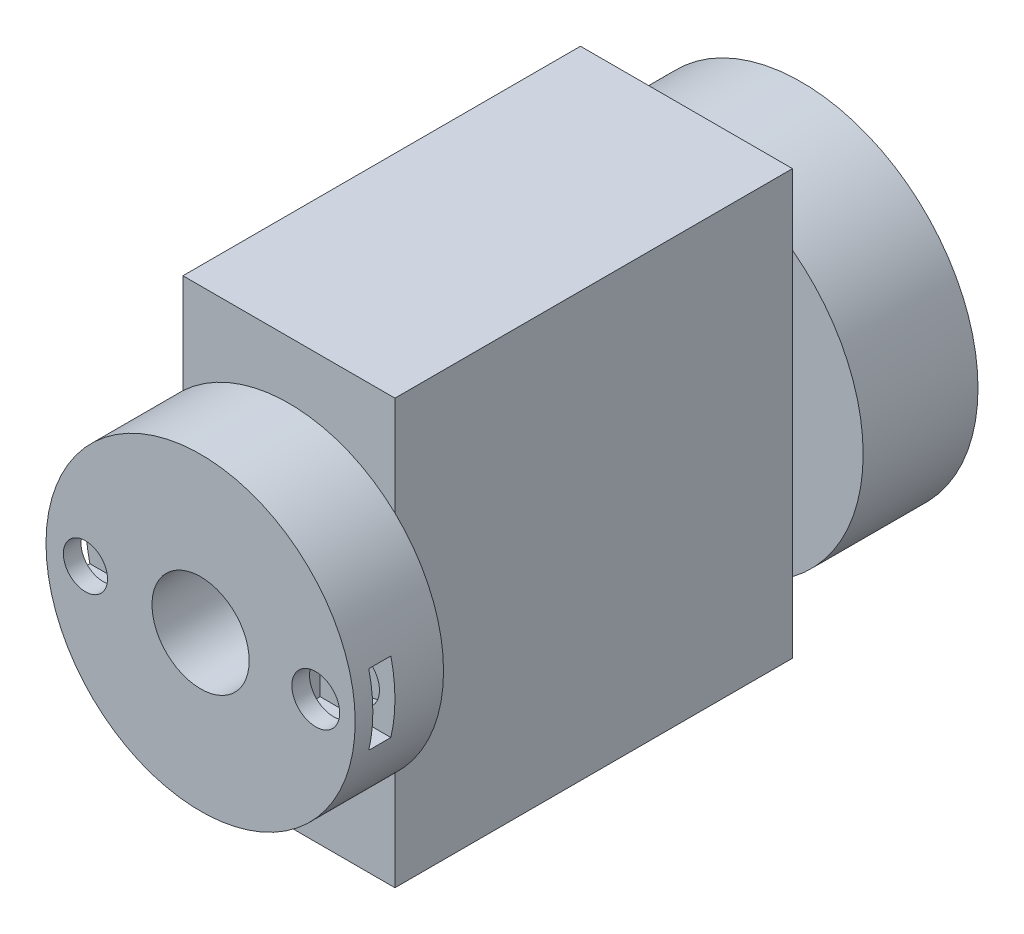
from build123d import *

# Parameters (mm, degrees)
ESQUISSE1_R                  = 17.5
BOSS_EXTRU_1_DEPTH           = 10
ESQUISSE3_W                  = 8
ESQUISSE3_H                  = 8
BOSS_EXTRU_3_DEPTH           = 4.5
ESQUISSE4_W                  = 2.5
ESQUISSE4_H                  = 8
ENL_V_MAT_EXTRU_1_DEPTH      = 1
ENL_V_MAT_EXTRU_1_DEPTH_BACK = 8
ESQUISSE5_R                  = 2.5
ENL_V_MAT_EXTRU_2_DEPTH      = 10.5
ESQUISSE6_W                  = 8
ESQUISSE6_H                  = 8
ESQUISSE6_R                  = 2.5
ENL_V_MAT_EXTRU_3_DEPTH      = 4.5
ESQUISSE7_W                  = 2.5
ESQUISSE7_H                  = 8
ENL_V_MAT_EXTRU_4_DEPTH      = 1
ENL_V_MAT_EXTRU_4_DEPTH_BACK = 8
ESQUISSE8_R                  = 2.707539361
ENL_V_MAT_EXTRU_5_DEPTH      = 10.5
ESQUISSE9_W                  = 8
ESQUISSE9_H                  = 8
ESQUISSE9_R                  = 2.707539361
ENL_V_MAT_EXTRU_6_DEPTH      = 4.5
ESQUISSE10_R                 = 5.5
ENL_V_MAT_EXTRU_7_DEPTH      = 11
ESQUISSE11_W                 = 24
ESQUISSE11_H                 = 48
BOSS_EXTRU_4_DEPTH           = 45
ESQUISSE12_R                 = 20
BOSS_EXTRU_5_DEPTH           = 13
ESQUISSE13_R                 = 11.5
ENL_V_MAT_EXTRU_8_DEPTH      = 8


with BuildPart() as part:
    # Esquisse1 → Boss.-Extru.1 (new body)
    with BuildSketch(Plane.XY):
        Circle(ESQUISSE1_R)
    extrude(amount=BOSS_EXTRU_1_DEPTH)

    # Esquisse3 → Boss.-Extru.3 (add)
    with BuildSketch(Plane.XY.offset(10)):
        with Locations((13.036725037, 0)):
            Rectangle(ESQUISSE3_W, ESQUISSE3_H)
        with Locations((-13.036725037, 0)):
            Rectangle(ESQUISSE3_W, ESQUISSE3_H)
    extrude(amount=BOSS_EXTRU_3_DEPTH)

    # Esquisse4 → Enlèv. mat.-Extru.1 (cut, two sides)
    with BuildSketch(Plane.ZY.offset(17.036725037)) as enl_v_mat_extru_1_sk:
        with Locations((6.75, 0)):
            Rectangle(ESQUISSE4_W, ESQUISSE4_H)
    extrude(amount=ENL_V_MAT_EXTRU_1_DEPTH, mode=Mode.SUBTRACT)
    extrude(enl_v_mat_extru_1_sk.sketch, amount=-ENL_V_MAT_EXTRU_1_DEPTH_BACK, mode=Mode.SUBTRACT)

    # Esquisse5 → Enlèv. mat.-Extru.2 (cut)
    with BuildSketch(Plane.XY.offset(14.5)):
        with Locations((-13.036725037, 0)):
            Circle(ESQUISSE5_R)
    extrude(amount=-ENL_V_MAT_EXTRU_2_DEPTH, mode=Mode.SUBTRACT)

    # Esquisse6 → Enlèv. mat.-Extru.3 (cut)
    with BuildSketch(Plane.XY.offset(14.5)):
        with Locations((-13.036725037, 0)):
            Rectangle(ESQUISSE6_W, ESQUISSE6_H)
        with Locations((-13.036725037, 0)):
            Circle(ESQUISSE6_R, mode=Mode.SUBTRACT)
    extrude(amount=-ENL_V_MAT_EXTRU_3_DEPTH, mode=Mode.SUBTRACT)

    # Esquisse7 → Enlèv. mat.-Extru.4 (cut, two sides)
    with BuildSketch(Plane(origin=(17.036725037, 0, 0), x_dir=(0, 0, -1), z_dir=(1, 0, 0))) as enl_v_mat_extru_4_sk:
        with Locations((-6.75, 0)):
            Rectangle(ESQUISSE7_W, ESQUISSE7_H)
    extrude(amount=ENL_V_MAT_EXTRU_4_DEPTH, mode=Mode.SUBTRACT)
    extrude(enl_v_mat_extru_4_sk.sketch, amount=-ENL_V_MAT_EXTRU_4_DEPTH_BACK, mode=Mode.SUBTRACT)

    # Esquisse8 → Enlèv. mat.-Extru.5 (cut)
    with BuildSketch(Plane.XY.offset(14.5)):
        with Locations((13.036725037, 0)):
            Circle(ESQUISSE8_R)
    extrude(amount=-ENL_V_MAT_EXTRU_5_DEPTH, mode=Mode.SUBTRACT)

    # Esquisse9 → Enlèv. mat.-Extru.6 (cut)
    with BuildSketch(Plane.XY.offset(14.5)):
        with Locations((13.036725037, 0)):
            Rectangle(ESQUISSE9_W, ESQUISSE9_H)
        with Locations((13.036725037, 0)):
            Circle(ESQUISSE9_R, mode=Mode.SUBTRACT)
    extrude(amount=-ENL_V_MAT_EXTRU_6_DEPTH, mode=Mode.SUBTRACT)

    # Esquisse10 → Enlèv. mat.-Extru.7 (cut, through all)
    with BuildSketch(Plane.XY.offset(10)):
        Circle(ESQUISSE10_R)
    extrude(amount=-ENL_V_MAT_EXTRU_7_DEPTH, mode=Mode.SUBTRACT)

    # Esquisse11 → Boss.-Extru.4 (add)
    with BuildSketch(Plane(origin=(0, 0, 0), x_dir=(-1, 0, 0), z_dir=(0, 0, -1))):
        Rectangle(ESQUISSE11_W, ESQUISSE11_H)
    extrude(amount=BOSS_EXTRU_4_DEPTH)

    # Esquisse12 → Boss.-Extru.5 (add)
    with BuildSketch(Plane(origin=(0, 0, -45), x_dir=(-1, 0, 0), z_dir=(0, 0, -1))):
        Circle(ESQUISSE12_R)
    extrude(amount=BOSS_EXTRU_5_DEPTH)

    # Esquisse13 → Enlèv. mat.-Extru.8 (cut)
    with BuildSketch(Plane(origin=(0, 0, -58), x_dir=(-1, 0, 0), z_dir=(0, 0, -1))):
        Circle(ESQUISSE13_R)
    extrude(amount=-ENL_V_MAT_EXTRU_8_DEPTH, mode=Mode.SUBTRACT)


solid = part.part
